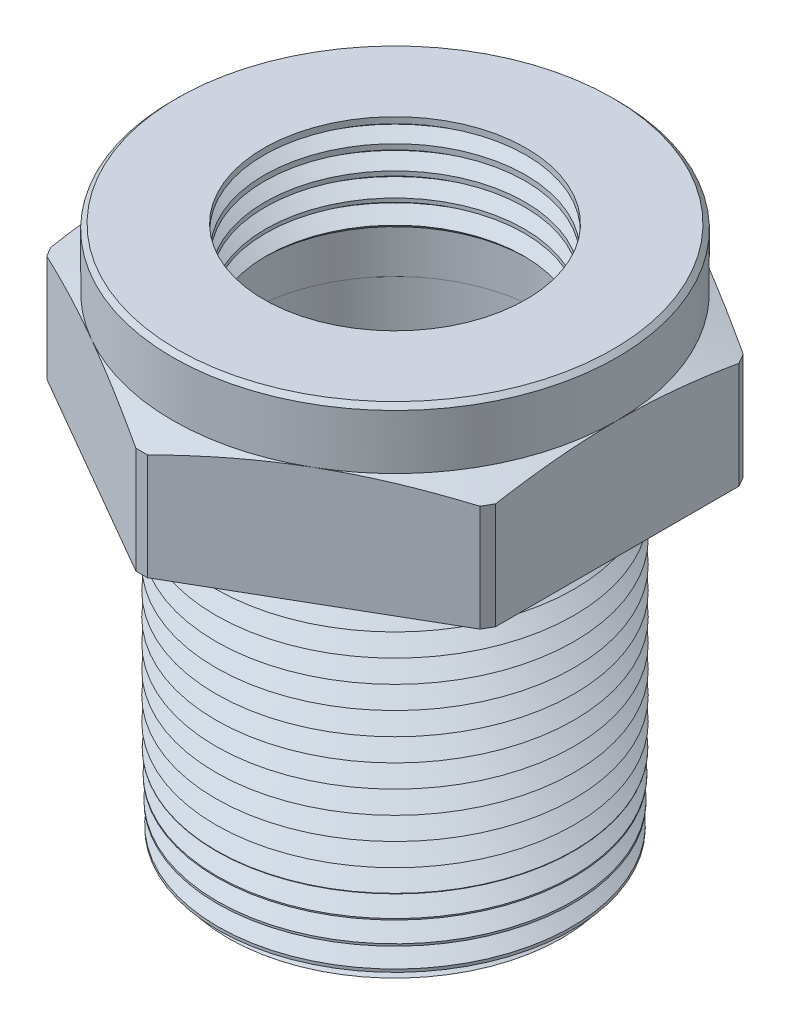
from build123d import *

# Parameters (mm, degrees)
SKETCH2_OUTSIDE_W  = 40.394
SKETCH2_OUTSIDE_H  = 40.394
CUT_EXTRUDE1_DEPTH = 10.906
SKETCH4_OUTSIDE_W  = 43.51
SKETCH4_OUTSIDE_H  = 46.994
SKETCH4_OUTSIDE_R  = 12.446
CUT_EXTRUDE3_DEPTH = 1.27
CUT_EXTRUDE3_DRAFT = -70
CHAMFER2_SIZE      = 0.247603347
CHAMFER2_SIZE2     = 0.254
LPATTERN1_COUNT    = 5
LPATTERN1_PITCH    = 1.27
LPATTERN2_COUNT    = 16
LPATTERN2_PITCH    = 1.27
CHAMFER3_SIZE      = 0.254


with BuildPart() as part:
    # Sketch1 → Revolve1 (revolve)
    with BuildSketch(Plane.XY, mode=Mode.PRIVATE) as revolve1_sk:
        Polygon((8.3312, 0), (9.888553298, 0), (10.414, 20.066), (14.18844, 20.066), (14.18844, 26.65984), (12.446, 26.65984), (12.446, 29.972), (7.342571073, 29.972), (7.2009, 24.5618), (8.281035, 24.5618), (8.281035, 21.5646), (8.3312, 21.5646), align=None)
    revolve(revolve1_sk.sketch.rotate(Axis((0, 0, 0), (0, 1, 0)), 90), axis=Axis((0, 0, 0), (0, 1, 0)))  # turned: the seam where the file's is

    # Sketch2 outside → Cut-Extrude1 (cut, through all)
    with BuildSketch(Plane.XZ.offset(-20.066)):
        Rectangle(SKETCH2_OUTSIDE_W, SKETCH2_OUTSIDE_H)
        Polygon((12.446, 7.18570145), (0, 14.371402901), (-12.446, 7.18570145), (-12.446, -7.18570145), (0, -14.371402901), (12.446, -7.18570145), align=None, mode=Mode.SUBTRACT)
    extrude(amount=-CUT_EXTRUDE1_DEPTH, mode=Mode.SUBTRACT)


with BuildPart() as cut_extrude3_tool:
    # Sketch4 outside → Cut-Extrude3 (with draft: the straight prism first)
    with BuildSketch(Plane(origin=(0, 26.65984, 0), x_dir=(-1, 0, 0), z_dir=(0, 1, 0))):
        Rectangle(SKETCH4_OUTSIDE_W, SKETCH4_OUTSIDE_H)
        with Locations(Location((0, 0, 0), (0, 0, 270))):  # turned: the seam where the file's is
            Circle(SKETCH4_OUTSIDE_R, mode=Mode.SUBTRACT)
    extrude(amount=-CUT_EXTRUDE3_DEPTH)
    # Cut-Extrude3: the draft: its side faces are tilted about the plane it starts from
    cut_extrude3_sides = [cut_extrude3_tool.faces().sort_by_distance(p)[0] for p in [
        (0, 26.02484, -23.497),
        (-21.755, 26.02484, 0),
        (0, 26.02484, 23.497),
        (21.755, 26.02484, 0),
        (0, 26.02484, 12.446),
    ]]
    draft(cut_extrude3_sides, Plane(origin=(0, 26.65984, 0), x_dir=(-1, 0, 0), z_dir=(0, 1, 0)), CUT_EXTRUDE3_DRAFT)


with BuildPart() as part_1:
    add(part.part)

    # Cut-Extrude3: cut by cut_extrude3_tool
    add(cut_extrude3_tool.part, mode=Mode.SUBTRACT)

    # Chamfer2
    chamfer2_edges = [part_1.edges().sort_by_distance(p)[0] for p in [
        (0, 24.5618, 7.2009),
    ]]
    chamfer2_side = [part_1.faces().sort_by_distance(p)[0] for p in [
        (0, 27.2669, 7.271735536),
    ]]
    chamfer(chamfer2_edges, length=CHAMFER2_SIZE, length2=CHAMFER2_SIZE2, reference=chamfer2_side[0])

    # Sketch7 → Cut-Revolve1 (revolve, cut)
    with BuildSketch(Plane.XY, mode=Mode.PRIVATE) as cut_revolve1_sk:
        Polygon((-7.2073815, 24.8093185), (-7.2359604, 25.900702651), (-8.001, 25.334603126), align=None)
    cut_revolve1 = revolve(cut_revolve1_sk.sketch.rotate(Axis((0, 0, 0), (0, 1, 0)), 270), axis=Axis((0, 0, 0), (0, 1, 0)), mode=Mode.SUBTRACT)  # turned: the seam where the file's is

    # LPattern1: Cut-Revolve1 ×5
    with Locations(*[(0, i * LPATTERN1_PITCH, 0) for i in range(1, LPATTERN1_COUNT)]):
        add(cut_revolve1, mode=Mode.SUBTRACT)

    # Sketch8 → Cut-Revolve2 (revolve, cut)
    with BuildSketch(Plane.XY, mode=Mode.PRIVATE) as cut_revolve2_sk:
        Polygon((-10.414, 20.066), (-9.121156991, 19.210285879), (-10.367443587, 18.28808231), align=None)
    cut_revolve2 = revolve(cut_revolve2_sk.sketch.rotate(Axis((0, 0, 0), (0, 1, 0)), 270), axis=Axis((0, 0, 0), (0, 1, 0)), mode=Mode.SUBTRACT)  # turned: the seam where the file's is

    # LPattern2: Cut-Revolve2 ×16
    with Locations(*[(0, -i * LPATTERN2_PITCH, 0) for i in range(1, LPATTERN2_COUNT)]):
        add(cut_revolve2, mode=Mode.SUBTRACT)

    # Chamfer3
    chamfer3_edges = [part_1.edges().sort_by_distance(p)[0] for p in [
        (0, 29.972, 12.446),
    ]]
    chamfer(chamfer3_edges, length=CHAMFER3_SIZE)


solid = part_1.part
